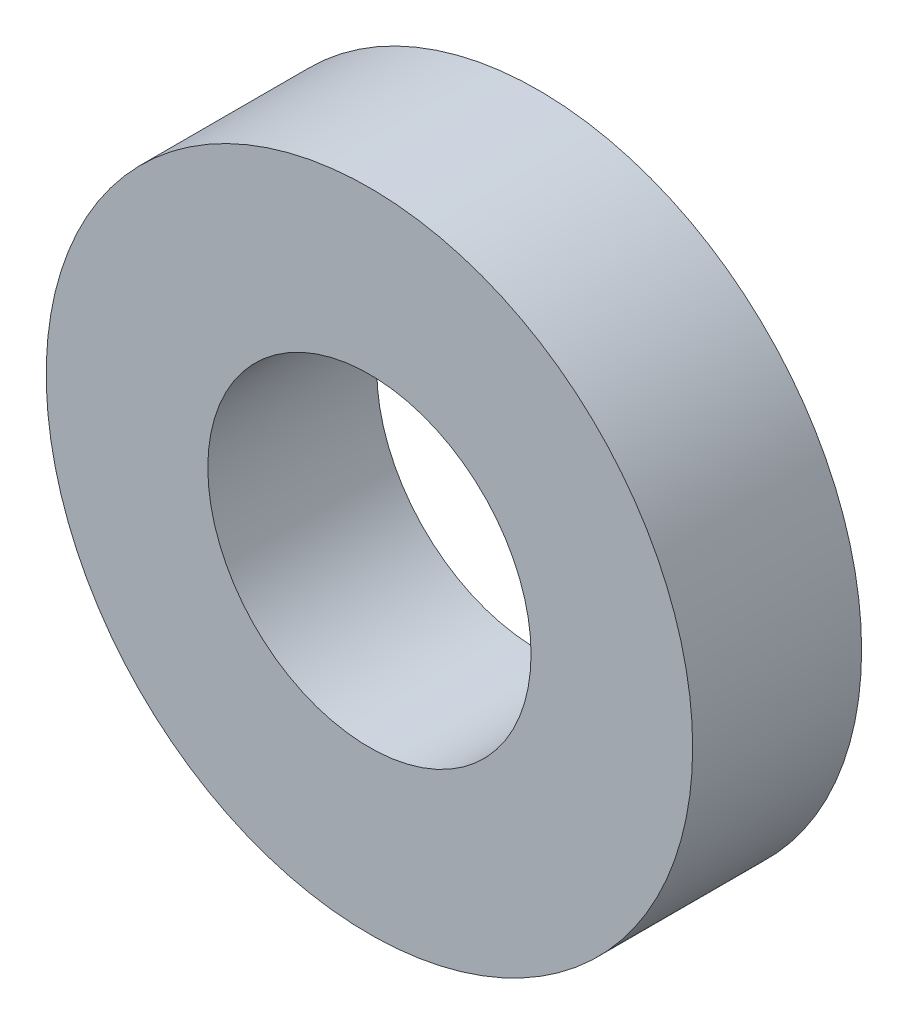
from build123d import *

# Parameters (mm, degrees)
SKETCH1_R           = 9.525
SKETCH1_R_2         = 4.7625
BOSS_EXTRUDE1_DEPTH = 4.9784


with BuildPart() as part:
    # Sketch1 → Boss-Extrude1 (new body)
    with BuildSketch(Plane.XY):
        Circle(SKETCH1_R)
        Circle(SKETCH1_R_2, mode=Mode.SUBTRACT)
    extrude(amount=BOSS_EXTRUDE1_DEPTH)


solid = part.part
